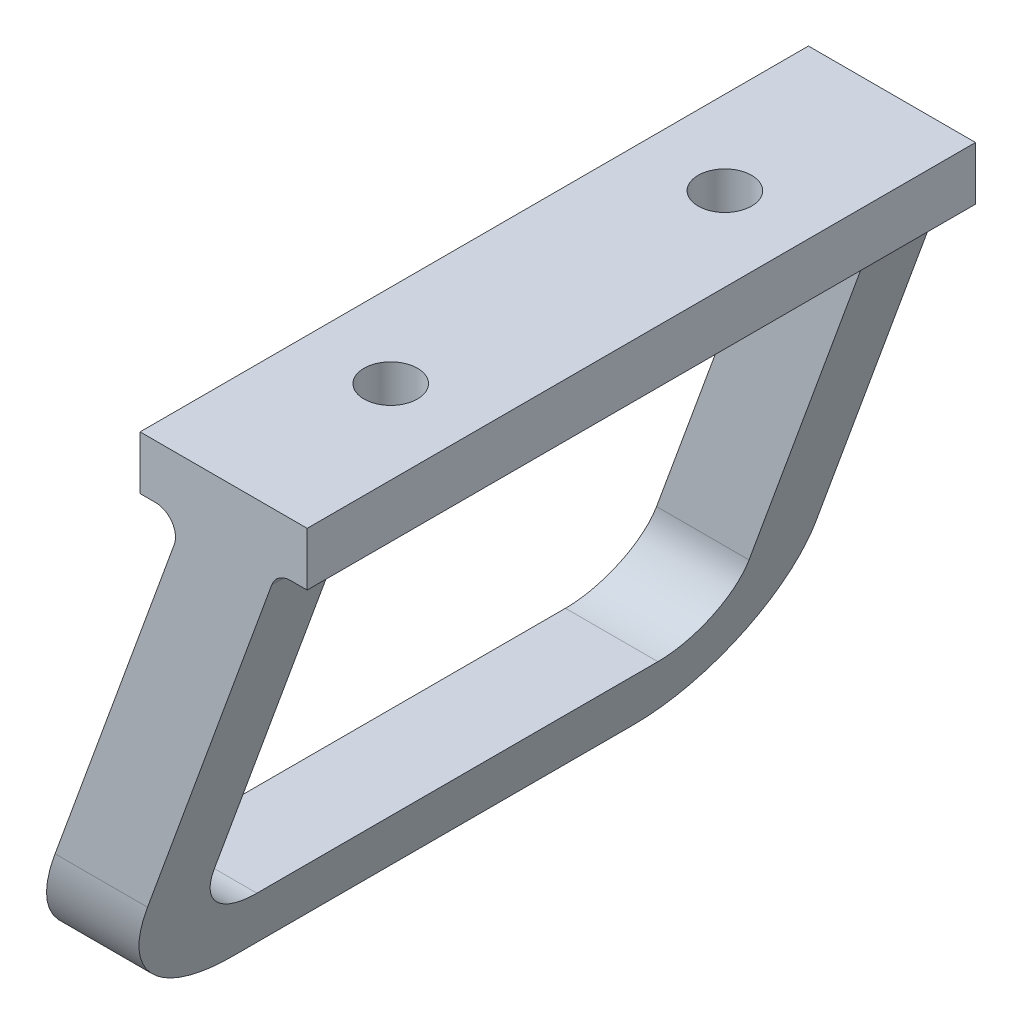
from build123d import *

# Parameters (mm, degrees)
BOSS_EXTRUDE1_DEPTH     = 100
CUT_EXTRUDE1_DEPTH      = 21
CUT_EXTRUDE1_DEPTH_BACK = 26
SKETCH5_R               = 4
CUT_EXTRUDE2_DEPTH      = 1
CUT_EXTRUDE2_DEPTH_BACK = 82.040159654


with BuildPart() as part:
    # Sketch1 → Boss-Extrude1 (new body)
    with BuildSketch(Plane.XY):
        with BuildLine():
            Line((7.200299815, -5.97393957), (-18.665688958, -77.040159654))
            Line((-18.665688958, -77.040159654), (-32.5, -77.040159654))
            Line((-32.5, -77.040159654), (-7.380922138, -8.02606043))
            ThreePointArc((-7.380922138, -8.02606043), (-7.742543867, -5.279270691), (-10.2, -4))
            Line((-10.2, -4), (-12.5, -4))
            Line((-12.5, -4), (-12.5, 4))
            Line((-12.5, 4), (12.5, 4))
            Line((12.5, 4), (12.5, -4))
            Line((12.5, -4), (10.019377677, -4))
            ThreePointArc((10.019377677, -4), (8.298648368, -4.542543867), (7.200299815, -5.97393957))
        make_face()
    extrude(amount=BOSS_EXTRUDE1_DEPTH)

    # Sketch4 → Cut-Extrude1 (cut, two sides)
    with BuildSketch(Plane.ZY.offset(12.5)) as cut_extrude1_sk:
        with BuildLine():
            ThreePointArc((20, -67.040159654), (12.928932188, -64.111227466), (10, -57.040159654))
            Line((10, -57.040159654), (10, -11))
            Line((10, -11), (90, -11))
            Line((90, -11), (90, -57.040159654))
            ThreePointArc((90, -57.040159654), (87.071067812, -64.111227466), (80, -67.040159654))
            Line((80, -67.040159654), (20, -67.040159654))
        make_face()
        with BuildLine():
            ThreePointArc((100, -57.040159654), (94.142135624, -71.182295278), (80, -77.040159654))
            Line((80, -77.040159654), (100, -77.040159654))
            Line((100, -77.040159654), (100, -57.040159654))
        make_face()
        with BuildLine():
            ThreePointArc((20, -77.040159654), (5.857864376, -71.182295278), (0, -57.040159654))
            Line((0, -57.040159654), (0, -77.040159654))
            Line((0, -77.040159654), (20, -77.040159654))
        make_face()
    extrude(amount=CUT_EXTRUDE1_DEPTH, mode=Mode.SUBTRACT)
    extrude(cut_extrude1_sk.sketch, amount=-CUT_EXTRUDE1_DEPTH_BACK, mode=Mode.SUBTRACT)

    # Sketch5 → Cut-Extrude2 (cut, two sides)
    with BuildSketch(Plane(origin=(0, 4, 0), x_dir=(1, 0, 0), z_dir=(0, 1, 0))) as cut_extrude2_sk:
        with Locations((0, -25)):
            Circle(SKETCH5_R)
        with Locations((0, -75)):
            Circle(SKETCH5_R)
    extrude(amount=CUT_EXTRUDE2_DEPTH, mode=Mode.SUBTRACT)
    extrude(cut_extrude2_sk.sketch, amount=-CUT_EXTRUDE2_DEPTH_BACK, mode=Mode.SUBTRACT)


solid = part.part
